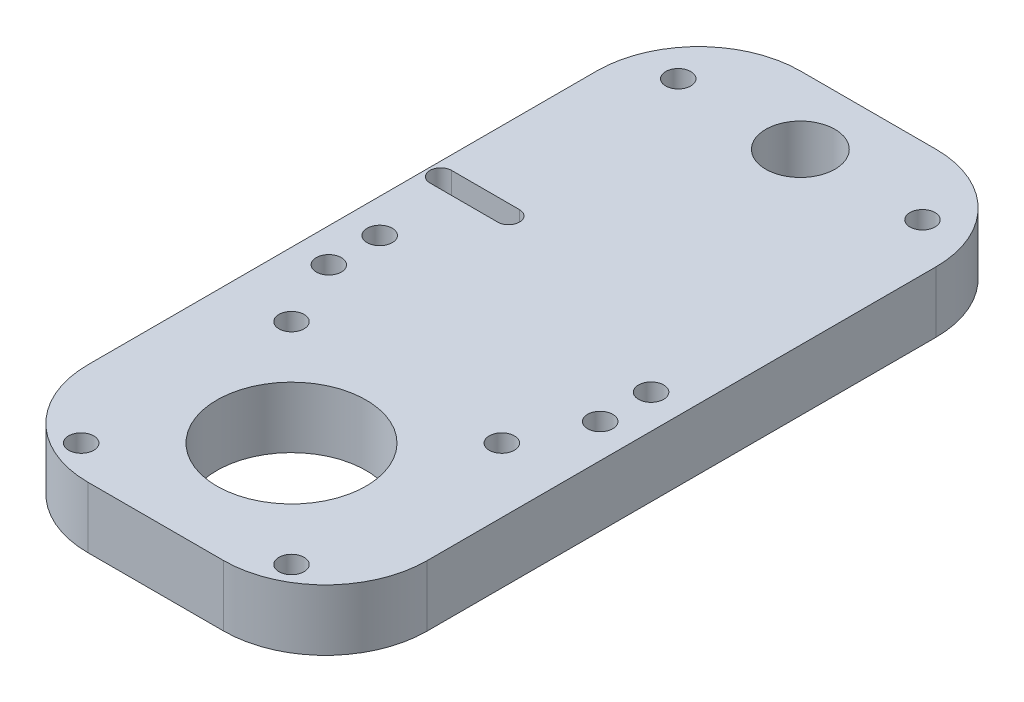
from build123d import *

# Parameters (mm, degrees)
SKETCH1_W           = 50
SKETCH1_H           = 105
BOSS_EXTRUDE1_DEPTH = 9
SKETCH2_R           = 11
SKETCH2_R_2         = 1.85
SKETCH2_R_3         = 5.1
CUT_EXTRUDE1_DEPTH  = 9
SKETCH3_R           = 1.85
CUT_EXTRUDE4_DEPTH  = 10
FILLET1_R           = 15


with BuildPart() as part:
    # Sketch1 → Boss-Extrude1 (new body)
    with BuildSketch(Plane(origin=(0, 0, 0), x_dir=(1, 0, 0), z_dir=(0, 1, 0))):
        with Locations((34.488967371, 40.084311239)):
            Rectangle(SKETCH1_W, SKETCH1_H)
    extrude(amount=BOSS_EXTRUDE1_DEPTH)

    # Sketch2 → Cut-Extrude1 (cut)
    with BuildSketch(Plane(origin=(0, 9, 0), x_dir=(1, 0, 0), z_dir=(0, 1, 0))):
        with Locations((34.488967371, 7.584311239)):
            Circle(SKETCH2_R)
        with Locations((49.988967371, 23.084311239)):
            Circle(SKETCH2_R_2)
        with Locations((18.988967371, -7.915688761)):
            Circle(SKETCH2_R_2)
        with Locations((49.988967371, -7.915688761)):
            Circle(SKETCH2_R_2)
        with Locations((18.988967371, 23.084311239)):
            Circle(SKETCH2_R_2)
        with Locations((52.488967371, 82.584311239)):
            Circle(SKETCH2_R_2)
        with Locations((34.488967371, 82.584311239)):
            Circle(SKETCH2_R_3)
        with Locations((16.488967371, 82.584311239)):
            Circle(SKETCH2_R_2)
        with BuildLine():
            Line((21.488967371, 50.984311239), (11.488967371, 50.984311239))
            ThreePointArc((11.488967371, 50.984311239), (9.888967371, 52.584311239), (11.488967371, 54.184311239))
            Line((11.488967371, 54.184311239), (21.488967371, 54.184311239))
            ThreePointArc((21.488967371, 54.184311239), (23.088967371, 52.584311239), (21.488967371, 50.984311239))
        make_face()
    extrude(amount=-CUT_EXTRUDE1_DEPTH, mode=Mode.SUBTRACT)

    # Sketch3 → Cut-Extrude4 (cut)
    with BuildSketch(Plane(origin=(0, 9, 0), x_dir=(1, 0, 0), z_dir=(0, 1, 0))):
        with Locations((14.488967371, 40.584311239)):
            Circle(SKETCH3_R)
        with Locations((54.488967371, 40.584311239)):
            Circle(SKETCH3_R)
        with Locations((54.488967371, 33.084311239)):
            Circle(SKETCH3_R)
        with Locations((14.488967371, 33.084311239)):
            Circle(SKETCH3_R)
    extrude(amount=-CUT_EXTRUDE4_DEPTH, mode=Mode.SUBTRACT)

    # Fillet1
    fillet1_edges = [part.edges().sort_by_distance(p)[0] for p in [
        (9.488967371, 4.5, -92.584311239),
        (59.488967371, 4.5, -92.584311239),
        (59.488967371, 4.5, 12.415688761),
        (9.488967371, 4.5, 12.415688761),
    ]]
    fillet(fillet1_edges, radius=FILLET1_R)


solid = part.part
